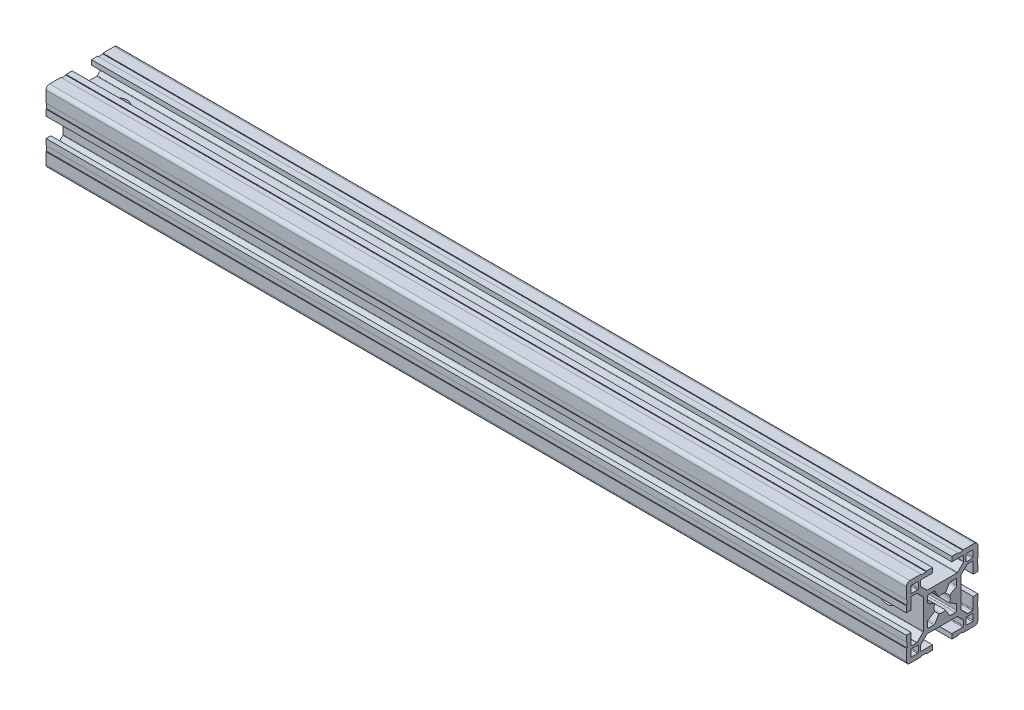
from build123d import *

# Parameters (mm, degrees)
QUADRADO_PF30_11_PERFIL_3030_CENTRO_M8_DEPTH = 360
ESBO_O2_R                                    = 3.95
CORTE_EXTRUS_O1_DEPTH                        = 362.039346099
ESBO_O3_R                                    = 3.95
CORTE_EXTRUS_O2_DEPTH                        = 362.039346198


with BuildPart() as part:
    # Sketch1 → Quadrado PF30-11 - PERFIL 3030 CENTRO M8(1) (new body)
    with BuildSketch(Plane.YZ):
        with BuildLine():
            Line((14.999995923, 6.599996803), (14.699995923, 6.599996803))
            Line((14.699995923, 6.599996803), (14.699995923, 8.799996803))
            Line((14.699995923, 8.799996803), (14.999995923, 8.799996803))
            Line((14.999995923, 8.799996803), (14.999995923, 13.499995825))
            ThreePointArc((14.999995923, 13.499995825), (14.560656066, 14.560656066), (13.499995825, 14.999995923))
            Line((13.499995825, 14.999995923), (8.799996818, 14.999995923))
            Line((8.799996818, 14.999995923), (8.799996818, 14.699995923))
            Line((8.799996818, 14.699995923), (6.599996818, 14.699995923))
            Line((6.599996818, 14.699995923), (6.599996818, 14.999995923))
            Line((6.599996818, 14.999995923), (4.0499987, 14.999995923))
            Line((4.0499987, 14.999995923), (4.0499987, 12.999995366))
            Line((4.0499987, 12.999995366), (8.699997649, 12.999995366))
            ThreePointArc((8.699997649, 12.999995366), (8.912129683, 12.9121274), (8.999997649, 12.699995366))
            Line((8.999997649, 12.699995366), (8.999997649, 10.679894006))
            ThreePointArc((8.999997649, 10.679894006), (8.977161511, 10.565088981), (8.912129691, 10.467761979))
            Line((8.912129691, 10.467761979), (6.432230191, 7.987862303))
            ThreePointArc((6.432230191, 7.987862303), (6.334903184, 7.922830472), (6.220098149, 7.89999433))
            Line((6.220098149, 7.89999433), (-6.220098149, 7.89999433))
            ThreePointArc((-6.220098149, 7.89999433), (-6.334903184, 7.922830472), (-6.432230191, 7.987862303))
            Line((-6.432230191, 7.987862303), (-8.912129691, 10.467761979))
            ThreePointArc((-8.912129691, 10.467761979), (-8.977161511, 10.565088981), (-8.999997649, 10.679894006))
            Line((-8.999997649, 10.679894006), (-8.999997649, 12.699995366))
            ThreePointArc((-8.999997649, 12.699995366), (-8.912129683, 12.9121274), (-8.699997649, 12.999995366))
            Line((-8.699997649, 12.999995366), (-4.0499987, 12.999995366))
            Line((-4.0499987, 12.999995366), (-4.0499987, 14.999995923))
            Line((-4.0499987, 14.999995923), (-6.599996818, 14.999995923))
            Line((-6.599996818, 14.999995923), (-6.599996818, 14.699995923))
            Line((-6.599996818, 14.699995923), (-8.799996818, 14.699995923))
            Line((-8.799996818, 14.699995923), (-8.799996818, 14.999995923))
            Line((-8.799996818, 14.999995923), (-13.499995825, 14.999995923))
            ThreePointArc((-13.499995825, 14.999995923), (-14.560656066, 14.560656066), (-14.999995923, 13.499995825))
            Line((-14.999995923, 13.499995825), (-14.999995923, 8.799996803))
            Line((-14.999995923, 8.799996803), (-14.699995923, 8.799996803))
            Line((-14.699995923, 8.799996803), (-14.699995923, 6.599996803))
            Line((-14.699995923, 6.599996803), (-14.999995923, 6.599996803))
            Line((-14.999995923, 6.599996803), (-14.999995923, 4.0499987))
            Line((-14.999995923, 4.0499987), (-12.999995366, 4.0499987))
            Line((-12.999995366, 4.0499987), (-12.999995366, 8.699997649))
            ThreePointArc((-12.999995366, 8.699997649), (-12.9121274, 8.912129683), (-12.699995366, 8.999997649))
            Line((-12.699995366, 8.999997649), (-10.679894006, 8.999997649))
            ThreePointArc((-10.679894006, 8.999997649), (-10.565088981, 8.977161511), (-10.467761979, 8.912129691))
            Line((-10.467761979, 8.912129691), (-7.987862303, 6.432230191))
            ThreePointArc((-7.987862303, 6.432230191), (-7.922830472, 6.334903184), (-7.89999433, 6.220098149))
            Line((-7.89999433, 6.220098149), (-7.89999433, -6.220098149))
            ThreePointArc((-7.89999433, -6.220098149), (-7.922830472, -6.334903184), (-7.987862303, -6.432230191))
            Line((-7.987862303, -6.432230191), (-10.467761979, -8.912129691))
            ThreePointArc((-10.467761979, -8.912129691), (-10.565088981, -8.977161511), (-10.679894006, -8.999997649))
            Line((-10.679894006, -8.999997649), (-12.699995366, -8.999997649))
            ThreePointArc((-12.699995366, -8.999997649), (-12.9121274, -8.912129683), (-12.999995366, -8.699997649))
            Line((-12.999995366, -8.699997649), (-12.999995366, -4.0499987))
            Line((-12.999995366, -4.0499987), (-14.999995923, -4.0499987))
            Line((-14.999995923, -4.0499987), (-14.999995923, -6.599996803))
            Line((-14.999995923, -6.599996803), (-14.699995923, -6.599996803))
            Line((-14.699995923, -6.599996803), (-14.699995923, -8.799996803))
            Line((-14.699995923, -8.799996803), (-14.999995923, -8.799996803))
            Line((-14.999995923, -8.799996803), (-14.999995923, -13.499995825))
            ThreePointArc((-14.999995923, -13.499995825), (-14.560656066, -14.560656066), (-13.499995825, -14.999995923))
            Line((-13.499995825, -14.999995923), (-8.799996818, -14.999995923))
            Line((-8.799996818, -14.999995923), (-8.799996818, -14.699995923))
            Line((-8.799996818, -14.699995923), (-6.599996818, -14.699995923))
            Line((-6.599996818, -14.699995923), (-6.599996818, -14.999995923))
            Line((-6.599996818, -14.999995923), (-4.0499987, -14.999995923))
            Line((-4.0499987, -14.999995923), (-4.0499987, -12.999995366))
            Line((-4.0499987, -12.999995366), (-8.699997649, -12.999995366))
            ThreePointArc((-8.699997649, -12.999995366), (-8.912129683, -12.9121274), (-8.999997649, -12.699995366))
            Line((-8.999997649, -12.699995366), (-8.999997649, -10.679894006))
            ThreePointArc((-8.999997649, -10.679894006), (-8.977161511, -10.565088981), (-8.912129691, -10.467761979))
            Line((-8.912129691, -10.467761979), (-6.432230191, -7.987862303))
            ThreePointArc((-6.432230191, -7.987862303), (-6.334903184, -7.922830472), (-6.220098149, -7.89999433))
            Line((-6.220098149, -7.89999433), (6.220098149, -7.89999433))
            ThreePointArc((6.220098149, -7.89999433), (6.334903184, -7.922830472), (6.432230191, -7.987862303))
            Line((6.432230191, -7.987862303), (8.912129691, -10.467761979))
            ThreePointArc((8.912129691, -10.467761979), (8.977161511, -10.565088981), (8.999997649, -10.679894006))
            Line((8.999997649, -10.679894006), (8.999997649, -12.699995366))
            ThreePointArc((8.999997649, -12.699995366), (8.912129683, -12.9121274), (8.699997649, -12.999995366))
            Line((8.699997649, -12.999995366), (4.0499987, -12.999995366))
            Line((4.0499987, -12.999995366), (4.0499987, -14.999995923))
            Line((4.0499987, -14.999995923), (6.599996818, -14.999995923))
            Line((6.599996818, -14.999995923), (6.599996818, -14.699995923))
            Line((6.599996818, -14.699995923), (8.799996818, -14.699995923))
            Line((8.799996818, -14.699995923), (8.799996818, -14.999995923))
            Line((8.799996818, -14.999995923), (13.499995825, -14.999995923))
            ThreePointArc((13.499995825, -14.999995923), (14.560656066, -14.560656066), (14.999995923, -13.499995825))
            Line((14.999995923, -13.499995825), (14.999995923, -8.799996803))
            Line((14.999995923, -8.799996803), (14.699995923, -8.799996803))
            Line((14.699995923, -8.799996803), (14.699995923, -6.599996803))
            Line((14.699995923, -6.599996803), (14.999995923, -6.599996803))
            Line((14.999995923, -6.599996803), (14.999995923, -4.0499987))
            Line((14.999995923, -4.0499987), (12.999995366, -4.0499987))
            Line((12.999995366, -4.0499987), (12.999995366, -8.699997649))
            ThreePointArc((12.999995366, -8.699997649), (12.9121274, -8.912129683), (12.699995366, -8.999997649))
            Line((12.699995366, -8.999997649), (10.679894006, -8.999997649))
            ThreePointArc((10.679894006, -8.999997649), (10.565088981, -8.977161511), (10.467761979, -8.912129691))
            Line((10.467761979, -8.912129691), (7.987862303, -6.432230191))
            ThreePointArc((7.987862303, -6.432230191), (7.922830472, -6.334903184), (7.89999433, -6.220098149))
            Line((7.89999433, -6.220098149), (7.89999433, 6.220098149))
            ThreePointArc((7.89999433, 6.220098149), (7.922830472, 6.334903184), (7.987862303, 6.432230191))
            Line((7.987862303, 6.432230191), (10.467761979, 8.912129691))
            ThreePointArc((10.467761979, 8.912129691), (10.565088981, 8.977161511), (10.679894006, 8.999997649))
            Line((10.679894006, 8.999997649), (12.699995366, 8.999997649))
            ThreePointArc((12.699995366, 8.999997649), (12.9121274, 8.912129683), (12.999995366, 8.699997649))
            Line((12.999995366, 8.699997649), (12.999995366, 4.0499987))
            Line((12.999995366, 4.0499987), (14.999995923, 4.0499987))
            Line((14.999995923, 4.0499987), (14.999995923, 6.599996803))
        make_face()
        with BuildLine():
            Line((-6.1, -3.425408784), (-6.1, -5.6))
            ThreePointArc((-6.1, -5.6), (-5.953553391, -5.953553391), (-5.6, -6.1))
            Line((-5.6, -6.1), (-3.425408784, -6.1))
            ThreePointArc((-3.425408784, -6.1), (-3.175408784, -6.033012702), (-2.992396082, -5.85))
            Line((-2.992396082, -5.85), (-1.402974441, -3.097040962))
            ThreePointArc((-1.402974441, -3.097040962), (0, -3.4), (1.402974441, -3.097040962))
            Line((1.402974441, -3.097040962), (2.992396082, -5.85))
            ThreePointArc((2.992396082, -5.85), (3.175408784, -6.033012702), (3.425408784, -6.1))
            Line((3.425408784, -6.1), (5.6, -6.1))
            ThreePointArc((5.6, -6.1), (5.953553391, -5.953553391), (6.1, -5.6))
            Line((6.1, -5.6), (6.1, -3.425408784))
            ThreePointArc((6.1, -3.425408784), (6.033012702, -3.175408784), (5.85, -2.992396082))
            Line((5.85, -2.992396082), (3.097040962, -1.402974441))
            ThreePointArc((3.097040962, -1.402974441), (3.4, 0), (3.097040962, 1.402974441))
            Line((3.097040962, 1.402974441), (5.85, 2.992396082))
            ThreePointArc((5.85, 2.992396082), (6.033012702, 3.175408784), (6.1, 3.425408784))
            Line((6.1, 3.425408784), (6.1, 5.6))
            ThreePointArc((6.1, 5.6), (5.953553391, 5.953553391), (5.6, 6.1))
            Line((5.6, 6.1), (3.425408784, 6.1))
            ThreePointArc((3.425408784, 6.1), (3.175408784, 6.033012702), (2.992396082, 5.85))
            Line((2.992396082, 5.85), (1.402974441, 3.097040962))
            ThreePointArc((1.402974441, 3.097040962), (0, 3.4), (-1.402974441, 3.097040962))
            Line((-1.402974441, 3.097040962), (-2.992396082, 5.85))
            ThreePointArc((-2.992396082, 5.85), (-3.175408784, 6.033012702), (-3.425408784, 6.1))
            Line((-3.425408784, 6.1), (-5.6, 6.1))
            ThreePointArc((-5.6, 6.1), (-5.953553391, 5.953553391), (-6.1, 5.6))
            Line((-6.1, 5.6), (-6.1, 3.425408784))
            ThreePointArc((-6.1, 3.425408784), (-6.033012702, 3.175408784), (-5.85, 2.992396082))
            Line((-5.85, 2.992396082), (-3.097040962, 1.402974441))
            ThreePointArc((-3.097040962, 1.402974441), (-3.4, 0), (-3.097040962, -1.402974441))
            Line((-3.097040962, -1.402974441), (-5.85, -2.992396082))
            ThreePointArc((-5.85, -2.992396082), (-6.033012702, -3.175408784), (-6.1, -3.425408784))
        make_face(mode=Mode.SUBTRACT)
        with BuildLine():
            Line((9.999995366, 12.699997649), (9.999995366, 10.299997649))
            ThreePointArc((9.999995366, 10.299997649), (10.087863331, 10.087865615), (10.299995366, 9.999997649))
            Line((10.299995366, 9.999997649), (12.699995366, 9.999997649))
            ThreePointArc((12.699995366, 9.999997649), (12.9121274, 10.087865615), (12.999995366, 10.299997649))
            Line((12.999995366, 10.299997649), (12.999995366, 12.699997649))
            ThreePointArc((12.999995366, 12.699997649), (12.9121274, 12.912129683), (12.699995366, 12.999997649))
            Line((12.699995366, 12.999997649), (10.299995366, 12.999997649))
            ThreePointArc((10.299995366, 12.999997649), (10.087863331, 12.912129683), (9.999995366, 12.699997649))
        make_face(mode=Mode.SUBTRACT)
        with BuildLine():
            Line((12.999995366, -12.699997649), (12.999995366, -10.299997649))
            ThreePointArc((12.999995366, -10.299997649), (12.9121274, -10.087865615), (12.699995366, -9.999997649))
            Line((12.699995366, -9.999997649), (10.299995366, -9.999997649))
            ThreePointArc((10.299995366, -9.999997649), (10.087863331, -10.087865615), (9.999995366, -10.299997649))
            Line((9.999995366, -10.299997649), (9.999995366, -12.699997649))
            ThreePointArc((9.999995366, -12.699997649), (10.087863331, -12.912129683), (10.299995366, -12.999997649))
            Line((10.299995366, -12.999997649), (12.699995366, -12.999997649))
            ThreePointArc((12.699995366, -12.999997649), (12.9121274, -12.912129683), (12.999995366, -12.699997649))
        make_face(mode=Mode.SUBTRACT)
        with BuildLine():
            Line((-10.299995366, -9.999997649), (-12.699995366, -9.999997649))
            ThreePointArc((-12.699995366, -9.999997649), (-12.9121274, -10.087865615), (-12.999995366, -10.299997649))
            Line((-12.999995366, -10.299997649), (-12.999995366, -12.699997649))
            ThreePointArc((-12.999995366, -12.699997649), (-12.9121274, -12.912129683), (-12.699995366, -12.999997649))
            Line((-12.699995366, -12.999997649), (-10.299995366, -12.999997649))
            ThreePointArc((-10.299995366, -12.999997649), (-10.087863331, -12.912129683), (-9.999995366, -12.699997649))
            Line((-9.999995366, -12.699997649), (-9.999995366, -10.299997649))
            ThreePointArc((-9.999995366, -10.299997649), (-10.087863331, -10.087865615), (-10.299995366, -9.999997649))
        make_face(mode=Mode.SUBTRACT)
        with BuildLine():
            Line((-12.999995366, 12.699997649), (-12.999995366, 10.299997649))
            ThreePointArc((-12.999995366, 10.299997649), (-12.9121274, 10.087865615), (-12.699995366, 9.999997649))
            Line((-12.699995366, 9.999997649), (-10.299995366, 9.999997649))
            ThreePointArc((-10.299995366, 9.999997649), (-10.087863331, 10.087865615), (-9.999995366, 10.299997649))
            Line((-9.999995366, 10.299997649), (-9.999995366, 12.699997649))
            ThreePointArc((-9.999995366, 12.699997649), (-10.087863331, 12.912129683), (-10.299995366, 12.999997649))
            Line((-10.299995366, 12.999997649), (-12.699995366, 12.999997649))
            ThreePointArc((-12.699995366, 12.999997649), (-12.9121274, 12.912129683), (-12.999995366, 12.699997649))
        make_face(mode=Mode.SUBTRACT)
    extrude(amount=QUADRADO_PF30_11_PERFIL_3030_CENTRO_M8_DEPTH)

    # Esboço2 → Corte-extrusão1 (cut, through all)
    with BuildSketch(Plane(origin=(0, 0, -7.89999433), x_dir=(-1, 0, 0), z_dir=(0, 0, -1))):
        with Locations(Location((-345, 0, 0), (0, 0, 90))):
            Circle(ESBO_O2_R)
    extrude(amount=-CORTE_EXTRUS_O1_DEPTH, mode=Mode.SUBTRACT)

    # Esboço3 → Corte-extrusão2 (cut, through all)
    with BuildSketch(Plane(origin=(0, 7.89999433, 0), x_dir=(1, 0, 0), z_dir=(0, 1, 0))):
        with Locations(Location((15, 0, 0), (0, 0, 270))):
            Circle(ESBO_O3_R)
    extrude(amount=-CORTE_EXTRUS_O2_DEPTH, mode=Mode.SUBTRACT)


solid = part.part
